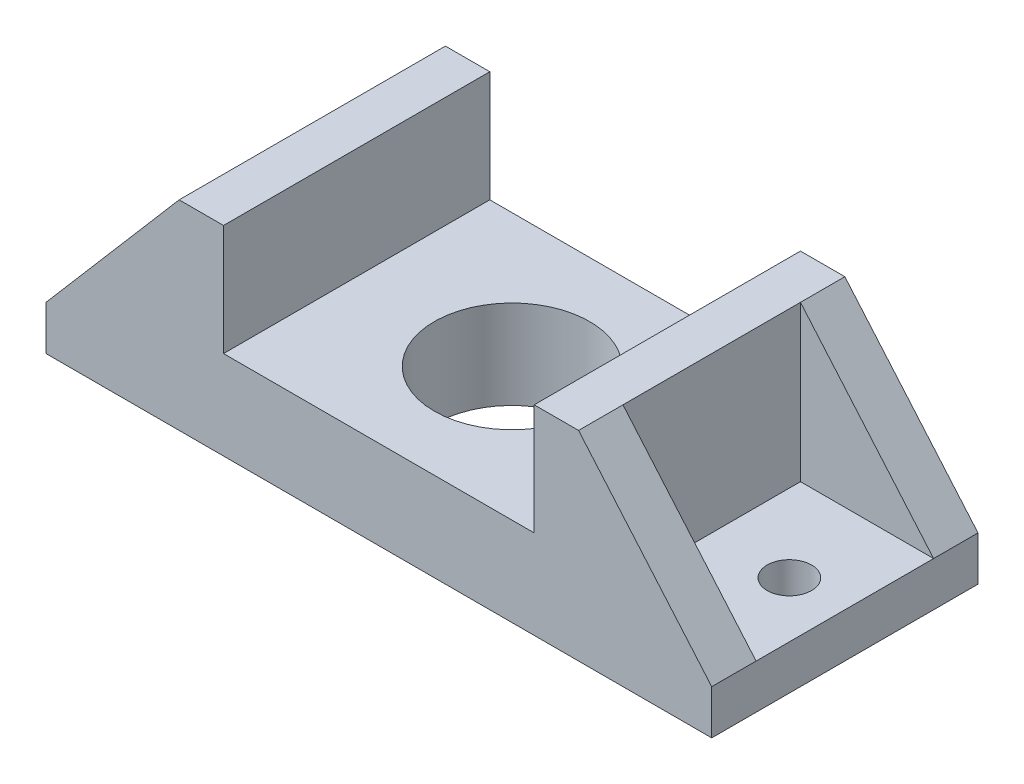
from build123d import *

# Parameters (mm, degrees)
IZIM1_W                     = 300
IZIM1_H                     = 120
Y_KSEKLIK_EKSTR_ZYON1_DEPTH = 20
IZIM2_W                     = 20
IZIM2_H                     = 120
Y_KSEKLIK_EKSTR_ZYON2_DEPTH = 70
IZIM3_W                     = 140
IZIM3_H                     = 120
Y_KSEKLIK_EKSTR_ZYON3_DEPTH = 20
Y_KSEKLIK_EKSTR_ZYON4_DEPTH = 20
AYNALAMA3_COPY_1_DEPTH      = 20
IZIM5_R                     = 35
KES_EKSTR_ZYON1_DEPTH       = 51
KES_EKSTR_ZYON1_DEPTH_BACK  = 41
IZIM6_R                     = 10
KES_EKSTR_ZYON2_DEPTH       = 20


with BuildPart() as part:
    # Çizim1 → Yükseklik-Ekstrüzyon1 (new body)
    with BuildSketch(Plane(origin=(0, 0, 0), x_dir=(1, 0, 0), z_dir=(0, 1, 0))):
        with Locations((150, 60)):
            Rectangle(IZIM1_W, IZIM1_H)
    extrude(amount=Y_KSEKLIK_EKSTR_ZYON1_DEPTH)

    # Çizim2 → Yükseklik-Ekstrüzyon2 (add)
    with BuildSketch(Plane(origin=(0, 20, 0), x_dir=(1, 0, 0), z_dir=(0, 1, 0))):
        with Locations((70, 60)):
            Rectangle(IZIM2_W, IZIM2_H)
    y_kseklik_ekstr_zyon2 = extrude(amount=Y_KSEKLIK_EKSTR_ZYON2_DEPTH)

    # Aynalama1: Yükseklik-Ekstrüzyon2 across plane
    add(y_kseklik_ekstr_zyon2.mirror(Plane.ZY.offset(-150)))

    # Çizim3 → Yükseklik-Ekstrüzyon3 (add)
    with BuildSketch(Plane(origin=(0, 20, 0), x_dir=(1, 0, 0), z_dir=(0, 1, 0))):
        with Locations((150, 60)):
            Rectangle(IZIM3_W, IZIM3_H)
    extrude(amount=Y_KSEKLIK_EKSTR_ZYON3_DEPTH)

    # Çizim4 → Yükseklik-Ekstrüzyon4 (add)
    with BuildSketch(Plane.XY):
        Polygon((0, 20), (60, 90), (60, 20), align=None)
    y_kseklik_ekstr_zyon4 = extrude(amount=-Y_KSEKLIK_EKSTR_ZYON4_DEPTH)

    # Aynalama2: Yükseklik-Ekstrüzyon4 across plane
    add(y_kseklik_ekstr_zyon4.mirror(Plane.XY.offset(-60)))

    # Aynalama3: Yükseklik-Ekstrüzyon4 across plane
    add(y_kseklik_ekstr_zyon4.mirror(Plane.ZY.offset(-150)))

    # Aynalama3 copy 1 sketch → Aynalama3 copy 1 (add)
    with BuildSketch(Plane(origin=(300, 0, -120), x_dir=(-1, 0, 0), z_dir=(0, 0, -1))):
        Polygon((0, 20), (60, 90), (60, 20), align=None)
    extrude(amount=-AYNALAMA3_COPY_1_DEPTH)

    # Çizim5 → Kes-Ekstrüzyon1 (cut, two sides)
    with BuildSketch(Plane(origin=(0, 40, 0), x_dir=(1, 0, 0), z_dir=(0, 1, 0))) as kes_ekstr_zyon1_sk:
        with Locations((150, 60)):
            Circle(IZIM5_R)
    extrude(amount=KES_EKSTR_ZYON1_DEPTH, mode=Mode.SUBTRACT)
    extrude(kes_ekstr_zyon1_sk.sketch, amount=-KES_EKSTR_ZYON1_DEPTH_BACK, mode=Mode.SUBTRACT)

    # Çizim6 → Kes-Ekstrüzyon2 (cut)
    with BuildSketch(Plane(origin=(0, 20, 0), x_dir=(1, 0, 0), z_dir=(0, 1, 0))):
        with Locations((25, 60)):
            Circle(IZIM6_R)
        with Locations((275, 60)):
            Circle(IZIM6_R)
    extrude(amount=-KES_EKSTR_ZYON2_DEPTH, mode=Mode.SUBTRACT)


solid = part.part
